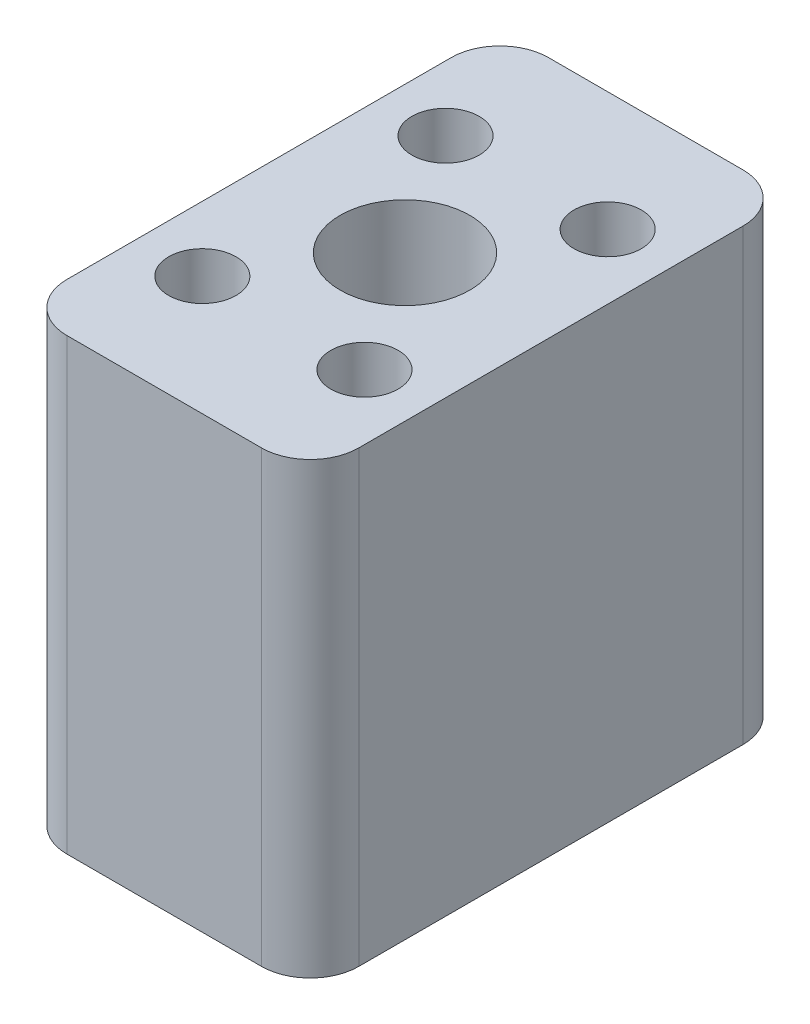
from build123d import *

# Parameters (mm, degrees)
SKETCH_1_W          = 18
SKETCH_1_H          = 29.7
EXTRUDE_1_DEPTH     = 27.7
SKETCH_2_R          = 2.075
CUT_EXTRUDE_1_DEPTH = 27.7
FILLET_1_R          = 3
SKETCH_3_R          = 4
CUT_EXTRUDE_2_DEPTH = 27.7


with BuildPart() as part:
    # 草图1 → 凸台-拉伸1 (new body)
    with BuildSketch(Plane(origin=(0, 0, 0), x_dir=(1, 0, 0), z_dir=(0, 1, 0))):
        Rectangle(SKETCH_1_W, SKETCH_1_H)
    extrude(amount=EXTRUDE_1_DEPTH)

    # 草图2 → 切除-拉伸1 (cut)
    with BuildSketch(Plane(origin=(0, 27.7, 0), x_dir=(1, 0, 0), z_dir=(0, 1, 0))):
        with Locations((5, 7.5)):
            Circle(SKETCH_2_R)
        with Locations((-5, 7.5)):
            Circle(SKETCH_2_R)
        with Locations((-5, -7.5)):
            Circle(SKETCH_2_R)
        with Locations((5, -7.5)):
            Circle(SKETCH_2_R)
    extrude(amount=-CUT_EXTRUDE_1_DEPTH, mode=Mode.SUBTRACT)

    # 圆角1
    fillet_1_edges = [part.edges().sort_by_distance(p)[0] for p in [
        (9, 13.85, 14.85),
        (-9, 13.85, 14.85),
        (-9, 13.85, -14.85),
        (9, 13.85, -14.85),
    ]]
    fillet(fillet_1_edges, radius=FILLET_1_R)

    # 草图3 → 切除-拉伸2 (cut)
    with BuildSketch(Plane(origin=(0, 27.7, 0), x_dir=(1, 0, 0), z_dir=(0, 1, 0))):
        Circle(SKETCH_3_R)
    extrude(amount=-CUT_EXTRUDE_2_DEPTH, mode=Mode.SUBTRACT)


solid = part.part
